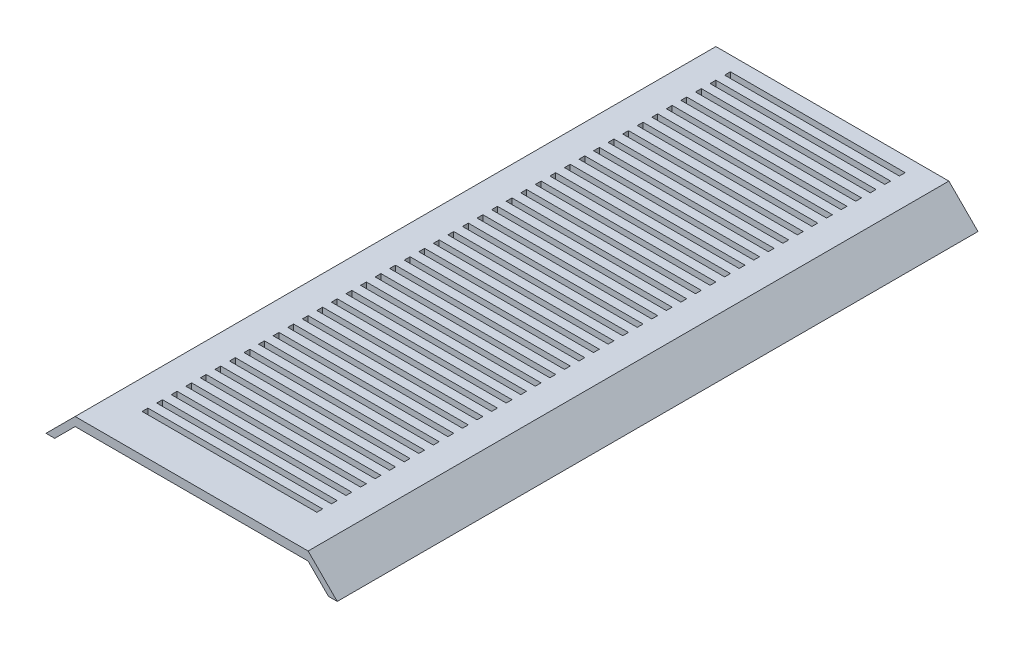
from build123d import *

# Parameters (mm, degrees)
SALIENTE_EXTRUIR1_DEPTH = 220
CROQUIS2_W              = 60
CROQUIS2_H              = 2
CORTAR_EXTRUIR1_DEPTH   = 10


with BuildPart() as part:
    # Croquis1 → Saliente-Extruir1 (new body)
    with BuildSketch(Plane.XY):
        Polygon((-47, 0), (-50, 0), (-40, 10), (40, 10), (50, 0), (47, 0), (40, 7), (-40, 7), align=None)
    extrude(amount=SALIENTE_EXTRUIR1_DEPTH)

    # Croquis2 → Cortar-Extruir1 (cut)
    with BuildSketch(Plane(origin=(0, 10, 0), x_dir=(1, 0, 0), z_dir=(0, 1, 0))):
        with Locations((0, -6)):
            Rectangle(CROQUIS2_W, CROQUIS2_H)
        with Locations((0, -11)):
            Rectangle(CROQUIS2_W, CROQUIS2_H)
        with Locations((0, -16)):
            Rectangle(CROQUIS2_W, CROQUIS2_H)
        with Locations((0, -21)):
            Rectangle(CROQUIS2_W, CROQUIS2_H)
        with Locations((0, -26)):
            Rectangle(CROQUIS2_W, CROQUIS2_H)
        with Locations((0, -31)):
            Rectangle(CROQUIS2_W, CROQUIS2_H)
        with Locations((0, -36)):
            Rectangle(CROQUIS2_W, CROQUIS2_H)
        with Locations((0, -41)):
            Rectangle(CROQUIS2_W, CROQUIS2_H)
        with Locations((0, -46)):
            Rectangle(CROQUIS2_W, CROQUIS2_H)
        with Locations((0, -51)):
            Rectangle(CROQUIS2_W, CROQUIS2_H)
        with Locations((0, -56)):
            Rectangle(CROQUIS2_W, CROQUIS2_H)
        with Locations((0, -61)):
            Rectangle(CROQUIS2_W, CROQUIS2_H)
        with Locations((0, -66)):
            Rectangle(CROQUIS2_W, CROQUIS2_H)
        with Locations((0, -71)):
            Rectangle(CROQUIS2_W, CROQUIS2_H)
        with Locations((0, -76)):
            Rectangle(CROQUIS2_W, CROQUIS2_H)
        with Locations((0, -81)):
            Rectangle(CROQUIS2_W, CROQUIS2_H)
        with Locations((0, -86)):
            Rectangle(CROQUIS2_W, CROQUIS2_H)
        with Locations((0, -91)):
            Rectangle(CROQUIS2_W, CROQUIS2_H)
        with Locations((0, -96)):
            Rectangle(CROQUIS2_W, CROQUIS2_H)
        with Locations((0, -101)):
            Rectangle(CROQUIS2_W, CROQUIS2_H)
        with Locations((0, -106)):
            Rectangle(CROQUIS2_W, CROQUIS2_H)
        with Locations((0, -111)):
            Rectangle(CROQUIS2_W, CROQUIS2_H)
        with Locations((0, -116)):
            Rectangle(CROQUIS2_W, CROQUIS2_H)
        with Locations((0, -121)):
            Rectangle(CROQUIS2_W, CROQUIS2_H)
        with Locations((0, -126)):
            Rectangle(CROQUIS2_W, CROQUIS2_H)
        with Locations((0, -131)):
            Rectangle(CROQUIS2_W, CROQUIS2_H)
        with Locations((0, -136)):
            Rectangle(CROQUIS2_W, CROQUIS2_H)
        with Locations((0, -141)):
            Rectangle(CROQUIS2_W, CROQUIS2_H)
        with Locations((0, -146)):
            Rectangle(CROQUIS2_W, CROQUIS2_H)
        with Locations((0, -151)):
            Rectangle(CROQUIS2_W, CROQUIS2_H)
        with Locations((0, -156)):
            Rectangle(CROQUIS2_W, CROQUIS2_H)
        with Locations((0, -161)):
            Rectangle(CROQUIS2_W, CROQUIS2_H)
        with Locations((0, -166)):
            Rectangle(CROQUIS2_W, CROQUIS2_H)
        with Locations((0, -171)):
            Rectangle(CROQUIS2_W, CROQUIS2_H)
        with Locations((0, -176)):
            Rectangle(CROQUIS2_W, CROQUIS2_H)
        with Locations((0, -181)):
            Rectangle(CROQUIS2_W, CROQUIS2_H)
        with Locations((0, -186)):
            Rectangle(CROQUIS2_W, CROQUIS2_H)
        with Locations((0, -191)):
            Rectangle(CROQUIS2_W, CROQUIS2_H)
        with Locations((0, -196)):
            Rectangle(CROQUIS2_W, CROQUIS2_H)
        with Locations((0, -201)):
            Rectangle(CROQUIS2_W, CROQUIS2_H)
        with Locations((0, -206)):
            Rectangle(CROQUIS2_W, CROQUIS2_H)
    extrude(amount=-CORTAR_EXTRUIR1_DEPTH, mode=Mode.SUBTRACT)


solid = part.part
